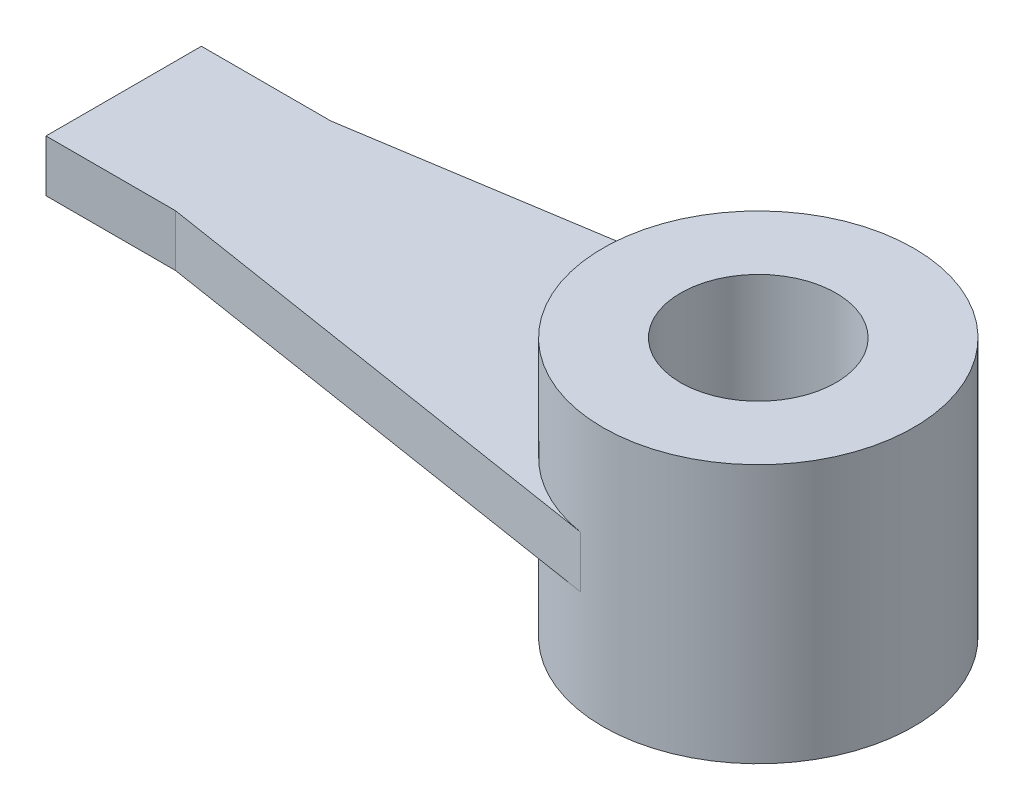
from build123d import *

# Parameters (mm, degrees)
SKETCH1_R           = 30
SKETCH1_R_2         = 15
BOSS_EXTRUDE1_DEPTH = 25
BOSS_EXTRUDE2_DEPTH = 5


with BuildPart() as part:
    # Sketch1 → Boss-Extrude1 (new body, symmetric)
    with BuildSketch(Plane(origin=(0, 0, 0), x_dir=(1, 0, 0), z_dir=(0, 1, 0))):
        with Locations(Location((0, 0, 0), (0, 0, 270))):  # turned: the seam where the file's is
            Circle(SKETCH1_R)
        with Locations(Location((0, 0, 0), (0, 0, 270))):  # turned: the seam where the file's is
            Circle(SKETCH1_R_2, mode=Mode.SUBTRACT)
    extrude(amount=BOSS_EXTRUDE1_DEPTH, both=True)

    # Sketch2 → Boss-Extrude2 (add, symmetric)
    with BuildSketch(Plane(origin=(0, 0, 0), x_dir=(1, 0, 0), z_dir=(0, 1, 0))):
        with BuildLine():
            Line((-122.5, 15), (-122.5, -15))
            Line((-122.5, -15), (-97.5, -15))
            Line((-97.5, -15), (-4.671688756, -29.634023084))
            ThreePointArc((-4.671688756, -29.634023084), (-30, 0), (-4.671688756, 29.634023084))
            Line((-4.671688756, 29.634023084), (-97.5, 15))
            Line((-97.5, 15), (-122.5, 15))
        make_face()
    extrude(amount=BOSS_EXTRUDE2_DEPTH, both=True)


solid = part.part
